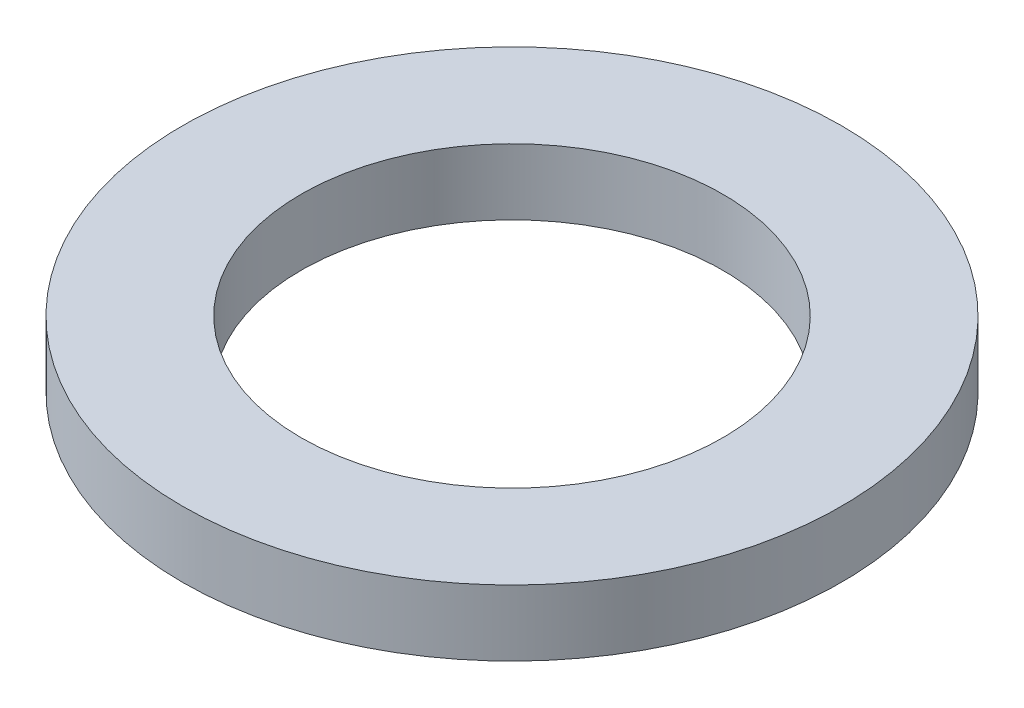
from build123d import *

# Parameters (mm, degrees)
SKETCH1_R           = 5
SKETCH1_R_2         = 3.2
BOSS_EXTRUDE1_DEPTH = 1


with BuildPart() as part:
    # Sketch1 → Boss-Extrude1 (new body)
    with BuildSketch(Plane(origin=(0, 0, 0), x_dir=(1, 0, 0), z_dir=(0, 1, 0))):
        Circle(SKETCH1_R)
        Circle(SKETCH1_R_2, mode=Mode.SUBTRACT)
    extrude(amount=BOSS_EXTRUDE1_DEPTH)


solid = part.part
